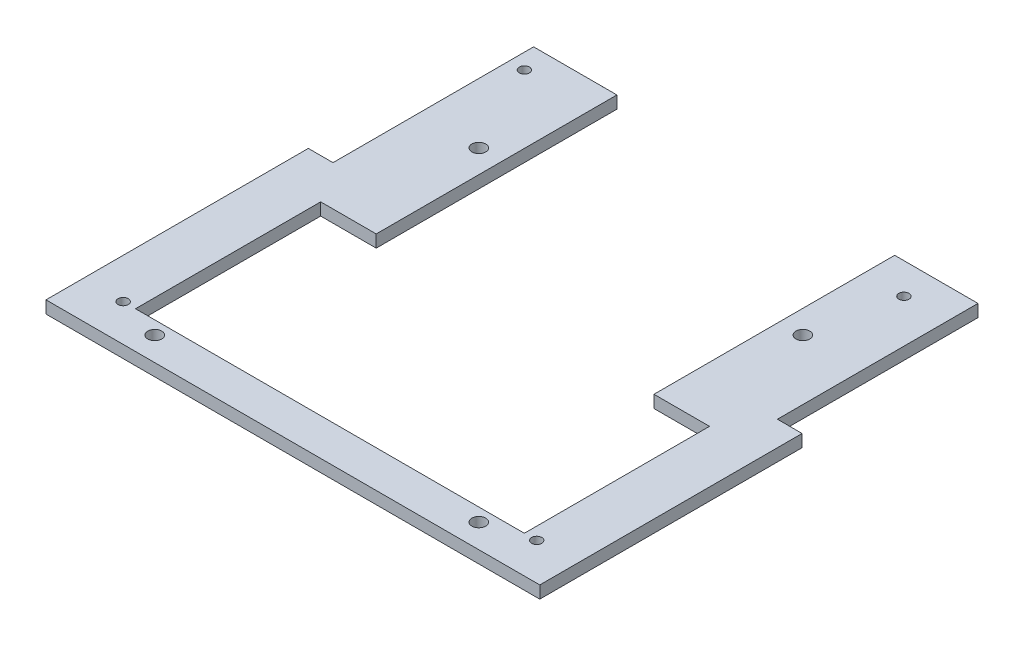
from build123d import *

# Parameters (mm, degrees)
SKETCH1_R      = 1.65
EXTRUDE1_DEPTH = 4
SKETCH3_R      = 2.25
EXTRUDE3_DEPTH = 4


with BuildPart() as part:
    # Sketch1 → Extrude1 (new body)
    with BuildSketch(Plane(origin=(0, 0, 0), x_dir=(1, 0, 0), z_dir=(0, 1, 0))):
        Polygon((-80, 10), (-80, -75), (80, -75), (80, 10), (72, 10), (72, 75), (45, 75), (45, -3), (63, -3), (63, -63), (-63, -63), (-63, -3), (-45, -3), (-45, 75), (-72, 75), (-72, 10), align=None)
        with Locations((-67, -63)):
            Circle(SKETCH1_R, mode=Mode.SUBTRACT)
        with Locations((67, -63)):
            Circle(SKETCH1_R, mode=Mode.SUBTRACT)
        with Locations((-67, 67)):
            Circle(SKETCH1_R, mode=Mode.SUBTRACT)
        with Locations((58, 65)):
            Circle(SKETCH1_R, mode=Mode.SUBTRACT)
    extrude(amount=EXTRUDE1_DEPTH)

    # Sketch3 → Extrude3 (cut)
    with BuildSketch(Plane(origin=(0, 4, 0), x_dir=(1, 0, 0), z_dir=(0, 1, 0))):
        with Locations((52.5, -67.259837658)):
            Circle(SKETCH3_R)
        with Locations((-52.5, -67.259837658)):
            Circle(SKETCH3_R)
        with Locations((52.5, 37.740162342)):
            Circle(SKETCH3_R)
        with Locations((-52.5, 37.740162342)):
            Circle(SKETCH3_R)
    extrude(amount=-EXTRUDE3_DEPTH, mode=Mode.SUBTRACT)


solid = part.part
